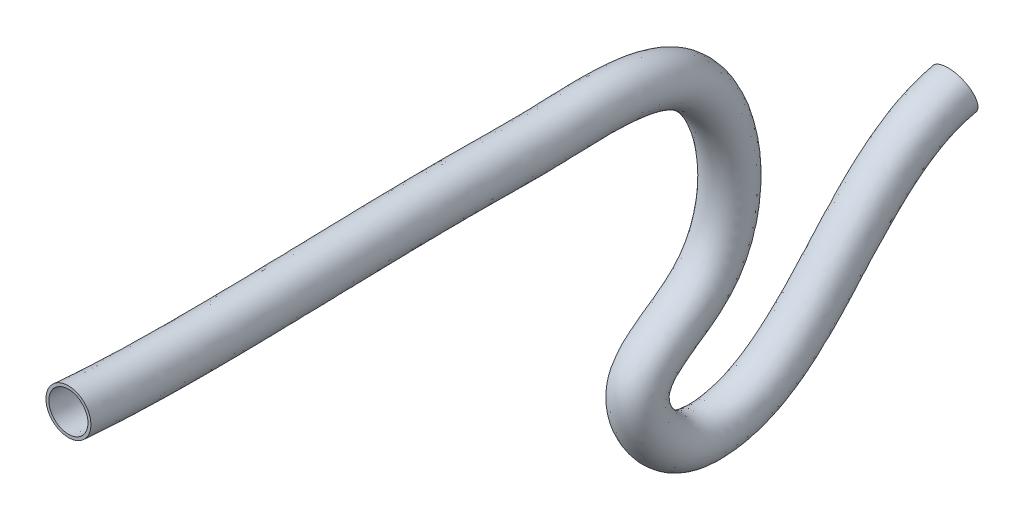
from build123d import *

# Parameters (mm, degrees)
SKETCH1_R   = 1.15
SKETCH1_R_2 = 1


with BuildPart() as part:
    # Sweep4: sweep along a path in Sketch5
    with BuildLine() as sweep4_path:  # in the path sketch's own coordinates; laid on its plane below (add() does not lay a ready-made edge on the line's plane)
        add(Edge.make_bspline(
            [(0, 0), (6.08280804, -0.549911405), (15.181195902, 0.142142065), (25.446480724, -0.087073075), (33.419462385, 0.728331996), (35.113871176, -10.344917078), (27.913013286, -12.796886438), (30.384731531, -17.174340963), (37.918735024, -17.425426587), (40.33895311, -9.434816796), (45.36753171, -8.363125708)],
            knots=[0, 0, 0, 0, 0.308652411, 0.366114428, 0.476791521, 0.616297932, 0.684526573, 0.73882291, 0.77674803, 1, 1, 1, 1], degree=3))
    # Sketch1 → Sweep4 (sweep)
    with BuildSketch(Plane.XY):
        Circle(SKETCH1_R)
        Circle(SKETCH1_R_2, mode=Mode.SUBTRACT)
    sweep(path=Plane(origin=(0, 0, 0), x_dir=(0, 0, -1), z_dir=(1, 0, 0)) * sweep4_path.line)


solid = part.part
